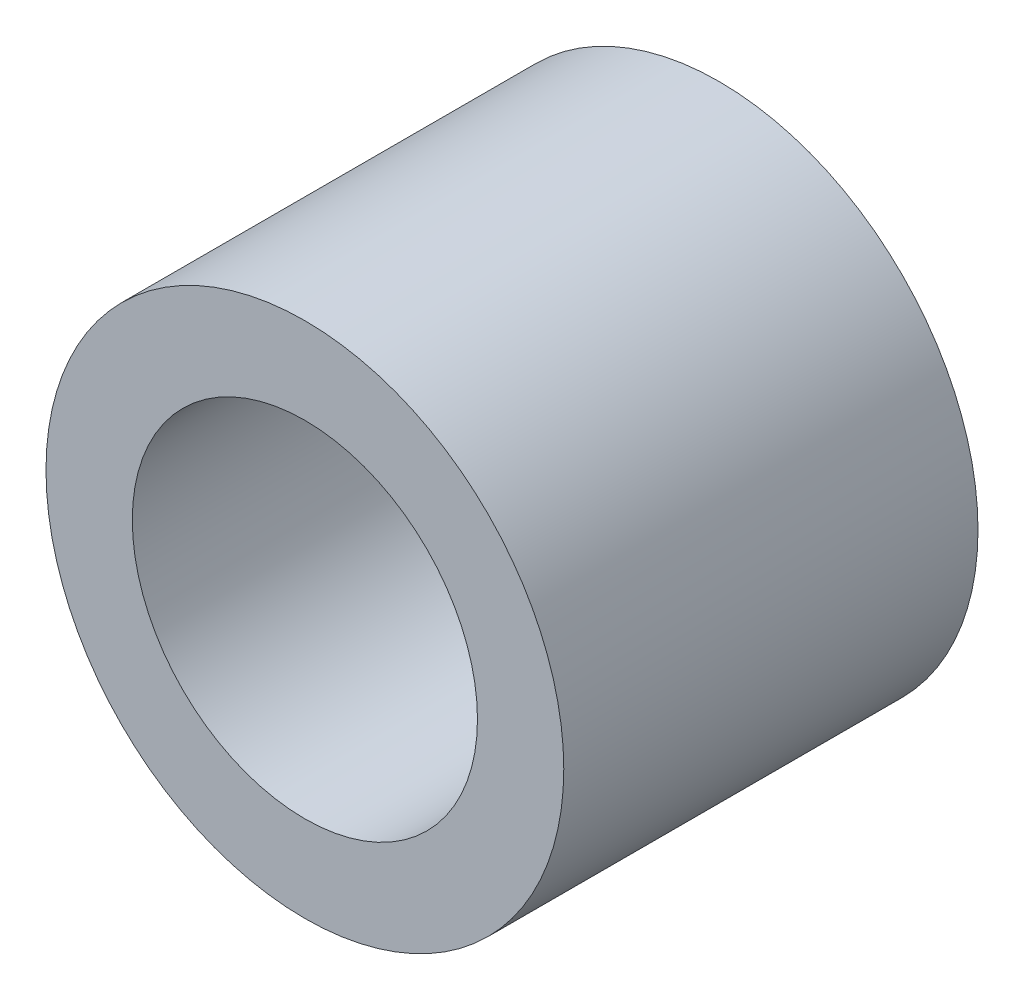
from build123d import *

# Parameters (mm, degrees)
SKETCH1_R           = 9.525
SKETCH1_R_2         = 6.35
BOSS_EXTRUDE1_DEPTH = 15.24


with BuildPart() as part:
    # Sketch1 → Boss-Extrude1 (new body)
    with BuildSketch(Plane.XY):
        Circle(SKETCH1_R)
        Circle(SKETCH1_R_2, mode=Mode.SUBTRACT)
    extrude(amount=BOSS_EXTRUDE1_DEPTH)


solid = part.part
